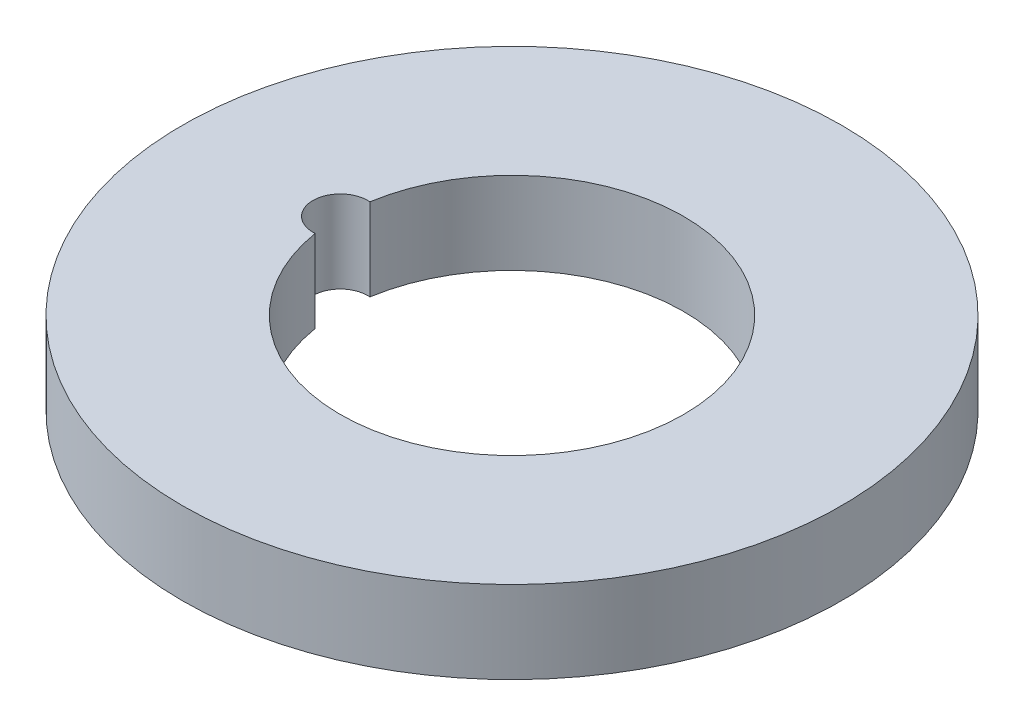
from build123d import *

# Parameters (mm, degrees)
IZIM1_R                     = 12
Y_KSEKLIK_EKSTR_ZYON1_DEPTH = 3


with BuildPart() as part:
    # Çizim1 → Yükseklik-Ekstrüzyon1 (new body)
    with BuildSketch(Plane(origin=(0, 0, 0), x_dir=(1, 0, 0), z_dir=(0, 1, 0))):
        Circle(IZIM1_R)
        with BuildLine():
            ThreePointArc((-6.17, -0.996794864), (6.25, 0), (-6.17, 0.996794864))
            ThreePointArc((-6.17, 0.996794864), (-7.25, 0), (-6.17, -0.996794864))
        make_face(mode=Mode.SUBTRACT)
    extrude(amount=Y_KSEKLIK_EKSTR_ZYON1_DEPTH)


solid = part.part
